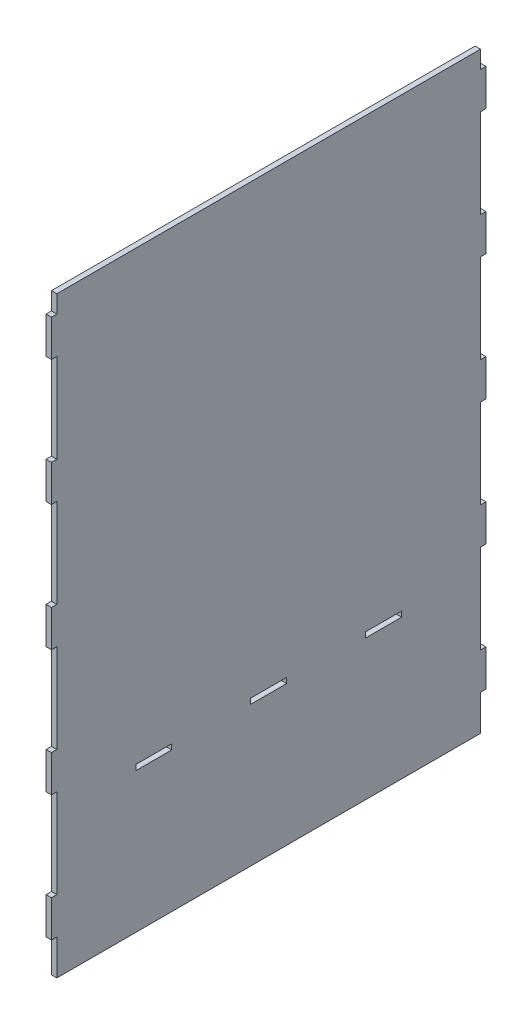
from build123d import *

# Parameters (mm, degrees)
SKETCH_1_W      = 20
SKETCH_1_H      = 3
EXTRUDE_1_DEPTH = 3


with BuildPart() as part:
    # Эскиз1 → Бобышка-Вытянуть1 (new body)
    with BuildSketch(Plane(origin=(0, 0, 0), x_dir=(0, 0, -1), z_dir=(1, 0, 0))):
        Polygon((-118, -165), (-118, -145.2), (-121, -145.2), (-121, -124.8), (-118, -124.8), (-118, -75.2), (-121, -75.2), (-121, -54.8), (-118, -54.8), (-118, -5.2), (-121, -5.2), (-121, 15.2), (-118, 15.2), (-118, 64.8), (-121, 64.8), (-121, 85.2), (-118, 85.2), (-118, 134.8), (-121, 134.8), (-121, 155.2), (-118, 155.2), (-118, 165), (118, 165), (118, 155.2), (121, 155.2), (121, 134.8), (118, 134.8), (118, 85.2), (121, 85.2), (121, 64.8), (118, 64.8), (118, 15.2), (121, 15.2), (121, -5.2), (118, -5.2), (118, -54.8), (121, -54.8), (121, -75.2), (118, -75.2), (118, -124.8), (121, -124.8), (121, -145.2), (118, -145.2), (118, -165), align=None)
        with Locations((-64, -85.5)):
            Rectangle(SKETCH_1_W, SKETCH_1_H, mode=Mode.SUBTRACT)
        with Locations((0, -85.5)):
            Rectangle(SKETCH_1_W, SKETCH_1_H, mode=Mode.SUBTRACT)
        with Locations((64, -85.5)):
            Rectangle(SKETCH_1_W, SKETCH_1_H, mode=Mode.SUBTRACT)
    extrude(amount=EXTRUDE_1_DEPTH)


solid = part.part
